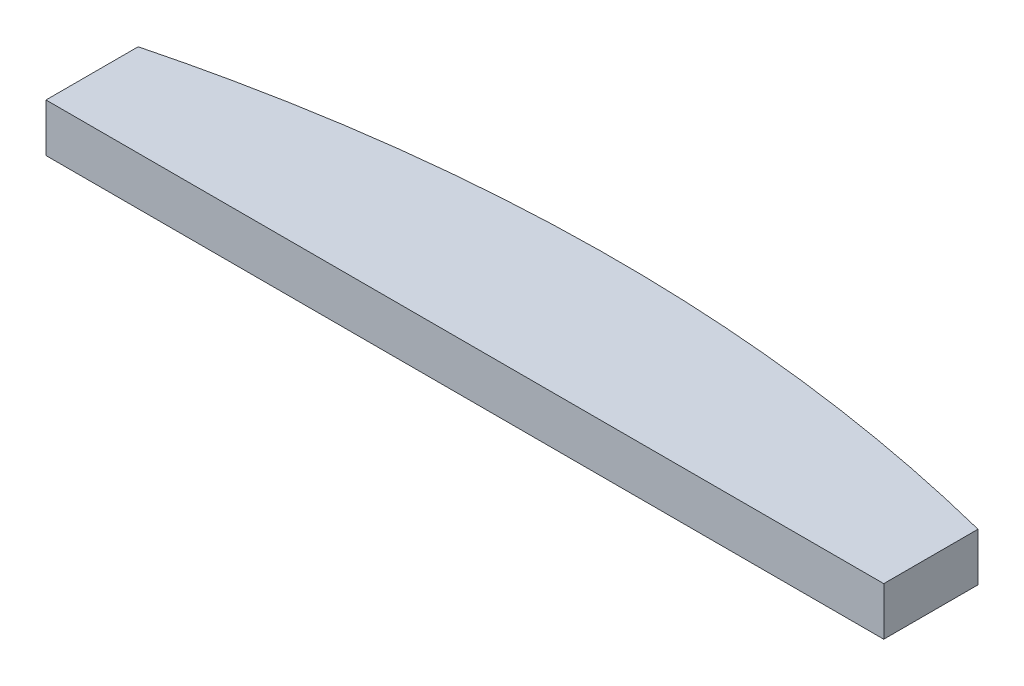
from build123d import *

# Parameters (mm, degrees)
SKETCH1_W           = 304.8
SKETCH1_H           = 76.2
BOSS_EXTRUDE1_DEPTH = 3.175
CUT_EXTRUDE3_DEPTH  = 0.254
CUT_EXTRUDE5_DEPTH  = 0.254
SKETCH3_2_OUTSIDE_W = 369.64
SKETCH3_2_OUTSIDE_H = 141.04
CUT_EXTRUDE8_DEPTH  = 315.196691105


with BuildPart() as part:
    # Sketch1 → Boss-Extrude1 (new body)
    with BuildSketch(Plane(origin=(0, 0, 0), x_dir=(1, 0, 0), z_dir=(0, 1, 0))):
        with Locations((-152.4, 38.1)):
            Rectangle(SKETCH1_W, SKETCH1_H)
    extrude(amount=BOSS_EXTRUDE1_DEPTH)

    # Sketch2 → Cut-Extrude3 (cut)
    with BuildSketch(Plane(origin=(0, 3.175, 0), x_dir=(1, 0, 0), z_dir=(0, 1, 0))):
        with BuildLine():
            Line((-304.8, 5.132354223), (-304.8, 0.390438323))
            add(Edge.make_bspline(
                [(-304.8, 0.390438323), (-303.821243343, 0.22923291), (-302.632591032, 0.100235841), (-301.136713645, 0)],
                knots=[0.767987957, 0.767987957, 0.767987957, 0.767987957, 1, 1, 1, 1], degree=3))
            Line((-301.136713645, 0), (-217.379871236, 0))
            add(Edge.make_bspline(
                [(-215.9, 0.210253502), (-216.602591478, 0.075926224), (-217.379871236, 0)],
                knots=[0.882956558, 0.882956558, 0.882956558, 1, 1, 1], degree=2))
            Line((-215.9, 0.210253502), (-215.9, 6.35))
            add(Edge.make_bspline(
                [(-304.8, 5.132354223), (-295.056068779, 7.913424716), (-284.63514545, 9.175759011), (-256.65451685, 7.910717471), (-231.983718042, 8.039058457), (-215.9, 6.35)],
                knots=[0.033341876, 0.033341876, 0.033341876, 0.033341876, 0.196819423, 0.285044024, 0.915587883, 0.915587883, 0.915587883, 0.915587883], degree=3))
        make_face()
        with BuildLine():
            Line((-304.748193138, 14.319973849), (-304.748193138, 9.578057948))
            add(Edge.make_bspline(
                [(-304.748193138, 9.578057948), (-303.76943648, 9.416852535), (-302.58078417, 9.287855466), (-301.084906782, 9.187619625)],
                knots=[0.767987957, 0.767987957, 0.767987957, 0.767987957, 1, 1, 1, 1], degree=3))
            Line((-301.084906782, 9.187619625), (-217.328064374, 9.187619625))
            add(Edge.make_bspline(
                [(-215.848193138, 9.397873128), (-216.550784616, 9.263545849), (-217.328064374, 9.187619625)],
                knots=[0.882956558, 0.882956558, 0.882956558, 1, 1, 1], degree=2))
            Line((-215.848193138, 9.397873128), (-215.848193138, 15.537619625))
            add(Edge.make_bspline(
                [(-304.748193138, 14.319973849), (-295.004261916, 17.101044341), (-284.583338588, 18.363378636), (-256.602709988, 17.098337097), (-231.93191118, 17.226678082), (-215.848193138, 15.537619625)],
                knots=[0.033341876, 0.033341876, 0.033341876, 0.033341876, 0.196819423, 0.285044024, 0.915587883, 0.915587883, 0.915587883, 0.915587883], degree=3))
        make_face()
        with BuildLine():
            Line((-304.77561062, 23.435546339), (-304.77561062, 18.693630439))
            add(Edge.make_bspline(
                [(-304.77561062, 18.693630439), (-303.796853962, 18.532425025), (-302.608201652, 18.403427957), (-301.112324264, 18.303192116)],
                knots=[0.767987957, 0.767987957, 0.767987957, 0.767987957, 1, 1, 1, 1], degree=3))
            Line((-301.112324264, 18.303192116), (-217.355481855, 18.303192116))
            add(Edge.make_bspline(
                [(-215.87561062, 18.513445618), (-216.578202097, 18.37911834), (-217.355481855, 18.303192116)],
                knots=[0.882956558, 0.882956558, 0.882956558, 1, 1, 1], degree=2))
            Line((-215.87561062, 18.513445618), (-215.87561062, 24.653192116))
            add(Edge.make_bspline(
                [(-304.77561062, 23.435546339), (-295.031679398, 26.216616832), (-284.61075607, 27.478951126), (-256.63012747, 26.213909587), (-231.959328661, 26.342250572), (-215.87561062, 24.653192116)],
                knots=[0.033341876, 0.033341876, 0.033341876, 0.033341876, 0.196819423, 0.285044024, 0.915587883, 0.915587883, 0.915587883, 0.915587883], degree=3))
        make_face()
        with BuildLine():
            Line((-304.723803757, 32.623165964), (-304.723803757, 27.881250064))
            add(Edge.make_bspline(
                [(-304.723803757, 27.881250064), (-303.7450471, 27.720044651), (-302.55639479, 27.591047582), (-301.060517402, 27.490811741)],
                knots=[0.767987957, 0.767987957, 0.767987957, 0.767987957, 1, 1, 1, 1], degree=3))
            Line((-301.060517402, 27.490811741), (-217.303674993, 27.490811741))
            add(Edge.make_bspline(
                [(-215.823803757, 27.701065244), (-216.526395235, 27.566737965), (-217.303674993, 27.490811741)],
                knots=[0.882956558, 0.882956558, 0.882956558, 1, 1, 1], degree=2))
            Line((-215.823803757, 27.701065244), (-215.823803757, 33.840811741))
            add(Edge.make_bspline(
                [(-304.723803757, 32.623165964), (-294.979872536, 35.404236457), (-284.558949208, 36.666570752), (-256.578320608, 35.401529213), (-231.907521799, 35.529870198), (-215.823803757, 33.840811741)],
                knots=[0.033341876, 0.033341876, 0.033341876, 0.033341876, 0.196819423, 0.285044024, 0.915587883, 0.915587883, 0.915587883, 0.915587883], degree=3))
        make_face()
        with BuildLine():
            Line((-304.692120731, 41.752034592), (-304.692120731, 37.010118692))
            add(Edge.make_bspline(
                [(-304.692120731, 37.010118692), (-303.713364073, 36.848913278), (-302.524711763, 36.71991621), (-301.028834375, 36.619680369)],
                knots=[0.767987957, 0.767987957, 0.767987957, 0.767987957, 1, 1, 1, 1], degree=3))
            Line((-301.028834375, 36.619680369), (-217.271991966, 36.619680369))
            add(Edge.make_bspline(
                [(-215.792120731, 36.829933871), (-216.494712209, 36.695606593), (-217.271991966, 36.619680369)],
                knots=[0.882956558, 0.882956558, 0.882956558, 1, 1, 1], degree=2))
            Line((-215.792120731, 36.829933871), (-215.792120731, 42.969680369))
            add(Edge.make_bspline(
                [(-304.692120731, 41.752034592), (-294.948189509, 44.533105085), (-284.527266181, 45.795439379), (-256.546637581, 44.53039784), (-231.875838773, 44.658738825), (-215.792120731, 42.969680369)],
                knots=[0.033341876, 0.033341876, 0.033341876, 0.033341876, 0.196819423, 0.285044024, 0.915587883, 0.915587883, 0.915587883, 0.915587883], degree=3))
        make_face()
        with BuildLine():
            Line((-304.640313869, 50.939654217), (-304.640313869, 46.197738317))
            add(Edge.make_bspline(
                [(-304.640313869, 46.197738317), (-303.661557211, 46.036532904), (-302.472904901, 45.907535835), (-300.977027513, 45.807299994)],
                knots=[0.767987957, 0.767987957, 0.767987957, 0.767987957, 1, 1, 1, 1], degree=3))
            Line((-300.977027513, 45.807299994), (-217.220185104, 45.807299994))
            add(Edge.make_bspline(
                [(-215.740313869, 46.017553497), (-216.442905346, 45.883226218), (-217.220185104, 45.807299994)],
                knots=[0.882956558, 0.882956558, 0.882956558, 1, 1, 1], degree=2))
            Line((-215.740313869, 46.017553497), (-215.740313869, 52.157299994))
            add(Edge.make_bspline(
                [(-304.640313869, 50.939654217), (-294.896382647, 53.72072471), (-284.475459319, 54.983059005), (-256.494830719, 53.718017466), (-231.82403191, 53.846358451), (-215.740313869, 52.157299994)],
                knots=[0.033341876, 0.033341876, 0.033341876, 0.033341876, 0.196819423, 0.285044024, 0.915587883, 0.915587883, 0.915587883, 0.915587883], degree=3))
        make_face()
        with BuildLine():
            Line((-304.66773135, 60.055226708), (-304.66773135, 55.313310807))
            add(Edge.make_bspline(
                [(-304.66773135, 55.313310807), (-303.688974693, 55.152105394), (-302.500322383, 55.023108326), (-301.004444995, 54.922872485)],
                knots=[0.767987957, 0.767987957, 0.767987957, 0.767987957, 1, 1, 1, 1], degree=3))
            Line((-301.004444995, 54.922872485), (-217.247602586, 54.922872485))
            add(Edge.make_bspline(
                [(-215.76773135, 55.133125987), (-216.470322828, 54.998798708), (-217.247602586, 54.922872485)],
                knots=[0.882956558, 0.882956558, 0.882956558, 1, 1, 1], degree=2))
            Line((-215.76773135, 55.133125987), (-215.76773135, 61.272872485))
            add(Edge.make_bspline(
                [(-304.66773135, 60.055226708), (-294.923800129, 62.836297201), (-284.502876801, 64.098631495), (-256.522248201, 62.833589956), (-231.851449392, 62.961930941), (-215.76773135, 61.272872485)],
                knots=[0.033341876, 0.033341876, 0.033341876, 0.033341876, 0.196819423, 0.285044024, 0.915587883, 0.915587883, 0.915587883, 0.915587883], degree=3))
        make_face()
        with BuildLine():
            Line((-304.615924488, 69.242846333), (-304.615924488, 64.500930433))
            add(Edge.make_bspline(
                [(-304.615924488, 64.500930433), (-303.637167831, 64.33972502), (-302.448515521, 64.210727951), (-300.952638133, 64.11049211)],
                knots=[0.767987957, 0.767987957, 0.767987957, 0.767987957, 1, 1, 1, 1], degree=3))
            Line((-300.952638133, 64.11049211), (-217.195795724, 64.11049211))
            add(Edge.make_bspline(
                [(-215.715924488, 64.320745612), (-216.418515966, 64.186418334), (-217.195795724, 64.11049211)],
                knots=[0.882956558, 0.882956558, 0.882956558, 1, 1, 1], degree=2))
            Line((-215.715924488, 64.320745612), (-215.715924488, 70.46049211))
            add(Edge.make_bspline(
                [(-304.615924488, 69.242846333), (-294.871993267, 72.023916826), (-284.451069938, 73.286251121), (-256.470441339, 72.021209581), (-231.79964253, 72.149550567), (-215.715924488, 70.46049211)],
                knots=[0.033341876, 0.033341876, 0.033341876, 0.033341876, 0.196819423, 0.285044024, 0.915587883, 0.915587883, 0.915587883, 0.915587883], degree=3))
        make_face()
        with BuildLine():
            Line((-215.183865707, 5.315478387), (-215.183865707, 0.573562486))
            add(Edge.make_bspline(
                [(-215.183865707, 0.573562486), (-214.20510905, 0.412357073), (-213.01645674, 0.283360005), (-211.520579352, 0.183124164)],
                knots=[0.767987957, 0.767987957, 0.767987957, 0.767987957, 1, 1, 1, 1], degree=3))
            Line((-211.520579352, 0.183124164), (-127.763736943, 0.183124164))
            add(Edge.make_bspline(
                [(-126.283865707, 0.393377666), (-126.986457185, 0.259050387), (-127.763736943, 0.183124164)],
                knots=[0.882956558, 0.882956558, 0.882956558, 1, 1, 1], degree=2))
            Line((-126.283865707, 0.393377666), (-126.283865707, 6.533124164))
            add(Edge.make_bspline(
                [(-215.183865707, 5.315478387), (-205.439934486, 8.09654888), (-195.019011157, 9.358883174), (-167.038382558, 8.093841635), (-142.367583749, 8.22218262), (-126.283865707, 6.533124164)],
                knots=[0.033341876, 0.033341876, 0.033341876, 0.033341876, 0.196819423, 0.285044024, 0.915587883, 0.915587883, 0.915587883, 0.915587883], degree=3))
        make_face()
        with BuildLine():
            Line((-215.132058845, 14.503098012), (-215.132058845, 9.761182112))
            add(Edge.make_bspline(
                [(-215.132058845, 9.761182112), (-214.153302188, 9.599976698), (-212.964649877, 9.47097963), (-211.46877249, 9.370743789)],
                knots=[0.767987957, 0.767987957, 0.767987957, 0.767987957, 1, 1, 1, 1], degree=3))
            Line((-211.46877249, 9.370743789), (-127.711930081, 9.370743789))
            add(Edge.make_bspline(
                [(-126.232058845, 9.580997291), (-126.934650323, 9.446670013), (-127.711930081, 9.370743789)],
                knots=[0.882956558, 0.882956558, 0.882956558, 1, 1, 1], degree=2))
            Line((-126.232058845, 9.580997291), (-126.232058845, 15.720743789))
            add(Edge.make_bspline(
                [(-215.132058845, 14.503098012), (-205.388127624, 17.284168505), (-194.967204295, 18.546502799), (-166.986575695, 17.28146126), (-142.315776887, 17.409802246), (-126.232058845, 15.720743789)],
                knots=[0.033341876, 0.033341876, 0.033341876, 0.033341876, 0.196819423, 0.285044024, 0.915587883, 0.915587883, 0.915587883, 0.915587883], degree=3))
        make_face()
        with BuildLine():
            Line((-215.159476327, 23.618670503), (-215.159476327, 18.876754602))
            add(Edge.make_bspline(
                [(-215.159476327, 18.876754602), (-214.180719669, 18.715549189), (-212.992067359, 18.58655212), (-211.496189971, 18.486316279)],
                knots=[0.767987957, 0.767987957, 0.767987957, 0.767987957, 1, 1, 1, 1], degree=3))
            Line((-211.496189971, 18.486316279), (-127.739347562, 18.486316279))
            add(Edge.make_bspline(
                [(-126.259476327, 18.696569782), (-126.962067804, 18.562242503), (-127.739347562, 18.486316279)],
                knots=[0.882956558, 0.882956558, 0.882956558, 1, 1, 1], degree=2))
            Line((-126.259476327, 18.696569782), (-126.259476327, 24.836316279))
            add(Edge.make_bspline(
                [(-215.159476327, 23.618670503), (-205.415545105, 26.399740996), (-194.994621777, 27.66207529), (-167.013993177, 26.397033751), (-142.343194369, 26.525374736), (-126.259476327, 24.836316279)],
                knots=[0.033341876, 0.033341876, 0.033341876, 0.033341876, 0.196819423, 0.285044024, 0.915587883, 0.915587883, 0.915587883, 0.915587883], degree=3))
        make_face()
        with BuildLine():
            Line((-215.107669465, 32.806290128), (-215.107669465, 28.064374228))
            add(Edge.make_bspline(
                [(-215.107669465, 28.064374228), (-214.128912807, 27.903168814), (-212.940260497, 27.774171746), (-211.444383109, 27.673935905)],
                knots=[0.767987957, 0.767987957, 0.767987957, 0.767987957, 1, 1, 1, 1], degree=3))
            Line((-211.444383109, 27.673935905), (-127.6875407, 27.673935905))
            add(Edge.make_bspline(
                [(-126.207669465, 27.884189407), (-126.910260942, 27.749862129), (-127.6875407, 27.673935905)],
                knots=[0.882956558, 0.882956558, 0.882956558, 1, 1, 1], degree=2))
            Line((-126.207669465, 27.884189407), (-126.207669465, 34.023935905))
            add(Edge.make_bspline(
                [(-215.107669465, 32.806290128), (-205.363738243, 35.587360621), (-194.942814915, 36.849694915), (-166.962186315, 35.584653376), (-142.291387506, 35.712994361), (-126.207669465, 34.023935905)],
                knots=[0.033341876, 0.033341876, 0.033341876, 0.033341876, 0.196819423, 0.285044024, 0.915587883, 0.915587883, 0.915587883, 0.915587883], degree=3))
        make_face()
    extrude(amount=-CUT_EXTRUDE3_DEPTH, mode=Mode.SUBTRACT)

    # Sketch3 → Cut-Extrude5 (cut)
    with BuildSketch(Plane(origin=(0, 3.175, 0), x_dir=(1, 0, 0), z_dir=(0, 1, 0))):
        with BuildLine():
            Line((-124.773731724, 0), (-73.973731724, 0))
            Line((-73.973731724, 0), (-73.973731724, 5.715))
            add(Edge.make_bspline(
                [(-124.773731724, 5.588), (-99.390849234, 12.627627449), (-73.973731724, 5.715)],
                knots=[0, 0, 0, 1, 1, 1], degree=2))
            Line((-124.773731724, 5.588), (-124.773731724, 0))
        make_face()
        with BuildLine():
            Line((-124.666073477, 9.555243731), (-73.866073477, 9.555243731))
            Line((-73.866073477, 9.555243731), (-73.866073477, 15.270243731))
            add(Edge.make_bspline(
                [(-124.666073477, 15.143243731), (-99.282006864, 21.683704535), (-73.866073477, 15.270243731)],
                knots=[0, 0, 0, 1, 1, 1], degree=2))
            Line((-124.666073477, 15.143243731), (-124.666073477, 9.555243731))
        make_face()
        with BuildLine():
            Line((-124.604715686, 19.129476511), (-73.804715686, 19.129476511))
            Line((-73.804715686, 19.129476511), (-73.804715686, 24.844476511))
            add(Edge.make_bspline(
                [(-124.604715686, 24.717476511), (-99.220649073, 31.257937315), (-73.804715686, 24.844476511)],
                knots=[0, 0, 0, 1, 1, 1], degree=2))
            Line((-124.604715686, 24.717476511), (-124.604715686, 19.129476511))
        make_face()
        with BuildLine():
            Line((-124.495240807, 28.763265862), (-73.695240807, 28.763265862))
            Line((-73.695240807, 28.763265862), (-73.695240807, 34.478265862))
            add(Edge.make_bspline(
                [(-124.495240807, 34.351265862), (-99.111174194, 40.891726665), (-73.695240807, 34.478265862)],
                knots=[0, 0, 0, 1, 1, 1], degree=2))
            Line((-124.495240807, 34.351265862), (-124.495240807, 28.763265862))
        make_face()
        with BuildLine():
            Line((-124.385765928, 38.397055212), (-73.585765928, 38.397055212))
            Line((-73.585765928, 38.397055212), (-73.585765928, 44.112055212))
            add(Edge.make_bspline(
                [(-124.385765928, 43.985055212), (-99.001699315, 50.525516016), (-73.585765928, 44.112055212)],
                knots=[0, 0, 0, 1, 1, 1], degree=2))
            Line((-124.385765928, 43.985055212), (-124.385765928, 38.397055212))
        make_face()
        with BuildLine():
            Line((-124.166816171, 49.235068231), (-73.366816171, 49.235068231))
            Line((-73.366816171, 49.235068231), (-73.366816171, 54.950068231))
            add(Edge.make_bspline(
                [(-124.166816171, 54.823068231), (-98.782749557, 61.363529035), (-73.366816171, 54.950068231)],
                knots=[0, 0, 0, 1, 1, 1], degree=2))
            Line((-124.166816171, 54.823068231), (-124.166816171, 49.235068231))
        make_face()
        with BuildLine():
            Line((-124.138868232, 59.013713621), (-73.338868232, 59.013713621))
            Line((-73.338868232, 59.013713621), (-73.338868232, 64.728713621))
            add(Edge.make_bspline(
                [(-124.138868232, 64.601713621), (-98.754801619, 71.142174425), (-73.338868232, 64.728713621)],
                knots=[0, 0, 0, 1, 1, 1], degree=2))
            Line((-124.138868232, 64.601713621), (-124.138868232, 59.013713621))
        make_face()
        with BuildLine():
            Line((-213.669393762, 38.449060159), (-162.869393762, 38.449060159))
            Line((-162.869393762, 38.449060159), (-162.869393762, 44.164060159))
            add(Edge.make_bspline(
                [(-213.669393762, 44.037060159), (-188.285327148, 50.577520962), (-162.869393762, 44.164060159)],
                knots=[0, 0, 0, 1, 1, 1], degree=2))
            Line((-213.669393762, 44.037060159), (-213.669393762, 38.449060159))
        make_face()
        with BuildLine():
            Line((-213.513008565, 49.239638781), (-162.713008565, 49.239638781))
            Line((-162.713008565, 49.239638781), (-162.713008565, 54.954638781))
            add(Edge.make_bspline(
                [(-213.513008565, 54.827638781), (-188.128941951, 61.368099585), (-162.713008565, 54.954638781)],
                knots=[0, 0, 0, 1, 1, 1], degree=2))
            Line((-213.513008565, 54.827638781), (-213.513008565, 49.239638781))
        make_face()
        with BuildLine():
            Line((-213.20023817, 60.030217404), (-162.40023817, 60.030217404))
            Line((-162.40023817, 60.030217404), (-162.40023817, 65.745217404))
            add(Edge.make_bspline(
                [(-213.20023817, 65.618217404), (-187.816171556, 72.158678208), (-162.40023817, 65.745217404)],
                knots=[0, 0, 0, 1, 1, 1], degree=2))
            Line((-213.20023817, 65.618217404), (-213.20023817, 60.030217404))
        make_face()
        Polygon((0, 76.2), (-31.75, 76.2), (-63.5, 0), (0, 0), align=None)
    extrude(amount=-CUT_EXTRUDE5_DEPTH, mode=Mode.SUBTRACT)

    # Sketch3_2 outside → Cut-Extrude8 (cut, through all)
    with BuildSketch(Plane(origin=(0, 3.175, 0), x_dir=(1, 0, 0), z_dir=(0, 1, 0))):
        with Locations((-152.4, 38.1)):
            Rectangle(SKETCH3_2_OUTSIDE_W, SKETCH3_2_OUTSIDE_H)
        with BuildLine():
            Line((-213.20023817, 65.618217404), (-213.20023817, 60.030217404))
            Line((-213.20023817, 60.030217404), (-162.40023817, 60.030217404))
            Line((-162.40023817, 60.030217404), (-162.40023817, 65.745217404))
            add(Edge.make_bspline(
                [(-213.20023817, 65.618217404), (-187.816171556, 72.158678208), (-162.40023817, 65.745217404)],
                knots=[0, 0, 0, 1, 1, 1], degree=2))
        make_face(mode=Mode.SUBTRACT)
    extrude(amount=-CUT_EXTRUDE8_DEPTH, mode=Mode.SUBTRACT)


solid = part.part
